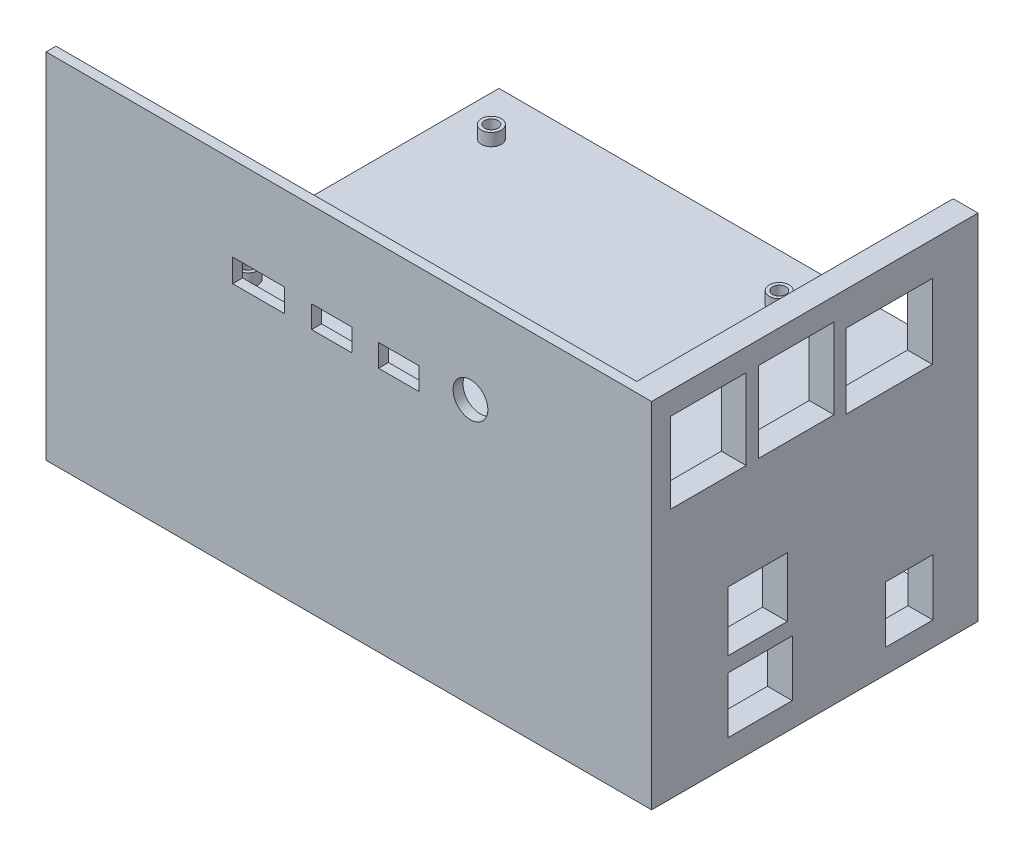
from build123d import *

# Parameters (mm, degrees)
MAIN_BODY_DEPTH                = 70
FAN_MOUNTS_DEPTH               = 5
SKETCH6_R                      = 30
FAN_HOLE_DEPTH                 = 5
SKETCH7_W                      = 65
SKETCH7_H                      = 1.25
BOTTOM_PLATE_DEPTH             = 127
SKETCH1_3_R                    = 2.54
SKETCH1_3_R_2                  = 1.6
ARDUINO_MOUNT_1_DEPTH          = 2.5
SKETCH1_4_R                    = 2.54
SKETCH1_4_R_2                  = 1.6
ARDUINO_MOUNT_2_DEPTH          = 2.5
SKETCH1_5_R                    = 2.54
SKETCH1_5_R_2                  = 1.6
ARDUINO_MOUNT_3_DEPTH          = 2.5
SKETCH1_6_R                    = 2.54
SKETCH1_6_R_2                  = 1.6
ARDUINO_MOUNT_4_DEPTH          = 2.5
SKETCH9_W                      = 12.985
SKETCH9_H                      = 11.3
ARDUINO_USB_B_DEPTH            = 5
SKETCH12_W                     = 9.5
SKETCH12_H                     = 11.4
ARDUION_POWER_HOLE_DEPTH       = 5
SKETCH28_W                     = 12
SKETCH28_H                     = 12
READER_COAX_DEPTH              = 5
SEPARATING_PLATE_DEPTH         = 62.5
PI_SEATS_DEPTH                 = 2.5
SKETCH14_W                     = 17.35
SKETCH14_H                     = 15
PI_ETHERNET_DEPTH              = 5
SKETCH16_W                     = 15.2
SKETCH16_H                     = 16.2
PI_USB_3_0_DEPTH               = 5
SKETCH18_W                     = 15.2
SKETCH18_H                     = 16.2
PI_USB_2_0_DEPTH               = 5
SKETCH19_R                     = 3.5
PI_AUDIO_PORT_DEPTH            = 2
SKETCH20_W                     = 8.1
SKETCH20_H                     = 4.5
PI_MICRO_HDMI_RIGHT_DEPTH      = 2
SKETCH21_W                     = 8.1
SKETCH21_H                     = 4.5
PI_MICRO_HDMI_LEFT_DEPTH       = 2
SKETCH22_W                     = 10.4
SKETCH22_H                     = 4.65
PI_USB_C_DEPTH                 = 2
SIDE_PANEL_OUT_DEPTH           = 1.5
SKETCH27_W                     = 127
SKETCH27_H                     = 71.25
SKETCH27_R                     = 3.5
SKETCH27_W_2                   = 8.1
SKETCH27_H_2                   = 4.5
SKETCH27_W_3                   = 10.4
SKETCH27_H_3                   = 4.65
MAKING_I_O_PANEL_THICKER_DEPTH = 0.75
REMOVE_START                   = -71.25
SKETCH35_W                     = 5
SKETCH35_H                     = 65.75
REMOVE_FAN_DEPTH               = 71.25


with BuildPart() as part:
    # Sketch1 → main body (new body)
    with BuildSketch(Plane(origin=(0, 0, 0), x_dir=(1, 0, 0), z_dir=(0, 1, 0))):
        Polygon((-46.184210526, 37.557328438), (-46.184210526, 38.807328438), (-62.226649752, 38.807328438), (-62.226649752, 31.576979723), (-57.226649752, 31.576979723), (-57.226649752, 37.557328438), align=None)
        Polygon((64.773350248, 38.807328438), (-46.184210526, 38.807328438), (-46.184210526, 37.557328438), (59.773350248, 37.557328438), (59.773350248, -24.942671562), (-57.226649752, -24.942671562), (-57.226649752, 31.576979723), (-62.226649752, 31.576979723), (-62.226649752, -26.192671562), (64.773350248, -26.192671562), align=None)
    extrude(amount=MAIN_BODY_DEPTH)

    # Sketch25 → fan mounts (cut)
    with BuildSketch(Plane.ZY.offset(62.226649752)):
        with BuildLine():
            Line((-31.333787438, 60), (-31.333787438, 62.15))
            ThreePointArc((-31.333787438, 62.15), (-32.854067018, 61.52027958), (-33.483787438, 60))
            Line((-33.483787438, 60), (-31.333787438, 60))
        make_face()
        with BuildLine():
            Line((-31.333787438, 57.85), (-31.333787438, 60))
            Line((-31.333787438, 60), (-33.483787438, 60))
            ThreePointArc((-33.483787438, 60), (-32.854067018, 58.47972042), (-31.333787438, 57.85))
        make_face()
        with BuildLine():
            Line((-29.183787438, 60), (-31.333787438, 60))
            Line((-31.333787438, 60), (-31.333787438, 57.85))
            ThreePointArc((-31.333787438, 57.85), (-29.813507858, 58.47972042), (-29.183787438, 60))
        make_face()
        with BuildLine():
            ThreePointArc((-29.183787438, 60), (-29.813507858, 61.52027958), (-31.333787438, 62.15))
            Line((-31.333787438, 62.15), (-31.333787438, 60))
            Line((-31.333787438, 60), (-29.183787438, 60))
        make_face()
        with BuildLine():
            ThreePointArc((-29.183787438, 10), (-29.813507858, 11.52027958), (-31.333787438, 12.15))
            Line((-31.333787438, 12.15), (-31.333787438, 10))
            Line((-31.333787438, 10), (-29.183787438, 10))
        make_face()
        with BuildLine():
            Line((-31.333787438, 10), (-31.333787438, 12.15))
            ThreePointArc((-31.333787438, 12.15), (-32.854067018, 8.47972042), (-29.183787438, 10))
            Line((-29.183787438, 10), (-31.333787438, 10))
        make_face()
        with BuildLine():
            ThreePointArc((20.816212562, 10), (20.186492142, 11.52027958), (18.666212562, 12.15))
            Line((18.666212562, 12.15), (18.666212562, 10))
            Line((18.666212562, 10), (16.516212562, 10))
            ThreePointArc((16.516212562, 10), (18.666212562, 7.85), (20.816212562, 10))
        make_face()
        with BuildLine():
            Line((18.666212562, 10), (18.666212562, 12.15))
            ThreePointArc((18.666212562, 12.15), (17.145932982, 11.52027958), (16.516212562, 10))
            Line((16.516212562, 10), (18.666212562, 10))
        make_face()
        with BuildLine():
            ThreePointArc((20.816212562, 60), (18.666212562, 62.15), (16.516212562, 60))
            Line((16.516212562, 60), (18.666212562, 60))
            Line((18.666212562, 60), (18.666212562, 57.85))
            ThreePointArc((18.666212562, 57.85), (20.186492142, 58.47972042), (20.816212562, 60))
        make_face()
        with BuildLine():
            Line((18.666212562, 60), (16.516212562, 60))
            ThreePointArc((16.516212562, 60), (17.145932982, 58.47972042), (18.666212562, 57.85))
            Line((18.666212562, 57.85), (18.666212562, 60))
        make_face()
    extrude(amount=-FAN_MOUNTS_DEPTH, mode=Mode.SUBTRACT)

    # Sketch6 → fan hole (cut)
    with BuildSketch(Plane.ZY.offset(62.226649752)):
        with Locations((-6.307328438, 34.968)):
            Circle(SKETCH6_R)
    extrude(amount=-FAN_HOLE_DEPTH, mode=Mode.SUBTRACT)

    # Sketch7 → bottom plate (add)
    with BuildSketch(Plane.ZY.offset(62.226649752)):
        with Locations((-6.307328438, -0.625)):
            Rectangle(SKETCH7_W, SKETCH7_H)
    extrude(amount=-BOTTOM_PLATE_DEPTH)

    # Sketch1_3 → arduino mount 1 (add)
    with BuildSketch(Plane(origin=(0, 0, 0), x_dir=(1, 0, 0), z_dir=(0, 1, 0))):
        with Locations((-7.472752953, 25.505147863)):
            Circle(SKETCH1_3_R)
        with Locations((-7.472752953, 25.505147863)):
            Circle(SKETCH1_3_R_2, mode=Mode.SUBTRACT)
    extrude(amount=ARDUINO_MOUNT_1_DEPTH)

    # Sketch1_4 → arduino mount 2 (add)
    with BuildSketch(Plane(origin=(0, 0, 0), x_dir=(1, 0, 0), z_dir=(0, 1, 0))):
        with Locations((-7.472752953, -2.394852137)):
            Circle(SKETCH1_4_R)
        with Locations((-7.472752953, -2.394852137)):
            Circle(SKETCH1_4_R_2, mode=Mode.SUBTRACT)
    extrude(amount=ARDUINO_MOUNT_2_DEPTH)

    # Sketch1_5 → arduino mount 3 (add)
    with BuildSketch(Plane(origin=(0, 0, 0), x_dir=(1, 0, 0), z_dir=(0, 1, 0))):
        with Locations((44.427247047, 30.205147863)):
            Circle(SKETCH1_5_R)
        with Locations((44.427247047, 30.205147863)):
            Circle(SKETCH1_5_R_2, mode=Mode.SUBTRACT)
    extrude(amount=ARDUINO_MOUNT_3_DEPTH)

    # Sketch1_6 → arduino mount 4 (add)
    with BuildSketch(Plane(origin=(0, 0, 0), x_dir=(1, 0, 0), z_dir=(0, 1, 0))):
        with Locations((43.327247047, -17.594852137)):
            Circle(SKETCH1_6_R)
        with Locations((43.327247047, -17.594852137)):
            Circle(SKETCH1_6_R_2, mode=Mode.SUBTRACT)
    extrude(amount=ARDUINO_MOUNT_4_DEPTH)

    # Sketch9 → arduino usb b (cut)
    with BuildSketch(Plane(origin=(64.773350248, 0, 0), x_dir=(0, 0, -1), z_dir=(1, 0, 0))):
        with Locations((-5.100171562, 9.3)):
            Rectangle(SKETCH9_W, SKETCH9_H)
    extrude(amount=-ARDUINO_USB_B_DEPTH, mode=Mode.SUBTRACT)

    # Sketch12 → arduion power hole (cut)
    with BuildSketch(Plane(origin=(64.773350248, 0, 0), x_dir=(0, 0, -1), z_dir=(1, 0, 0))):
        with Locations((24.957328438, 9.25)):
            Rectangle(SKETCH12_W, SKETCH12_H)
    extrude(amount=-ARDUION_POWER_HOLE_DEPTH, mode=Mode.SUBTRACT)

    # Sketch28 → reader coax (cut)
    with BuildSketch(Plane(origin=(64.773350248, 0, 0), x_dir=(0, 0, -1), z_dir=(1, 0, 0))):
        with Locations((-5.592671562, 23.95)):
            Rectangle(SKETCH28_W, SKETCH28_H)
    extrude(amount=-READER_COAX_DEPTH, mode=Mode.SUBTRACT)

    # clearance → separating plate (add)
    with BuildSketch(Plane.XY.offset(-37.557328438)):
        Polygon((21.752865488, 43), (59.773350248, 43), (59.773350248, 45), (-30.226649752, 45), (-30.226649752, 43), align=None)
    extrude(amount=SEPARATING_PLATE_DEPTH)

    # Sketch24 → pi seats (add)
    with BuildSketch(Plane(origin=(0, 45, 0), x_dir=(1, 0, 0), z_dir=(0, 1, 0))):
        with BuildLine():
            Line((-22.218946752, 29.111418438), (-22.218946752, 29.761418438))
            ThreePointArc((-22.218946752, 29.761418438), (-23.633160315, 29.175632), (-24.218946752, 27.761418438))
            Line((-24.218946752, 27.761418438), (-23.568946752, 27.761418438))
            ThreePointArc((-23.568946752, 27.761418438), (-23.173540907, 28.716012593), (-22.218946752, 29.111418438))
        make_face()
        with BuildLine():
            ThreePointArc((-20.218946752, 27.761418438), (-20.80473319, 29.175632), (-22.218946752, 29.761418438))
            Line((-22.218946752, 29.761418438), (-22.218946752, 29.111418438))
            ThreePointArc((-22.218946752, 29.111418438), (-21.264352598, 28.716012593), (-20.868946752, 27.761418438))
            Line((-20.868946752, 27.761418438), (-20.218946752, 27.761418438))
        make_face()
        with BuildLine():
            ThreePointArc((-22.218946752, 25.761418438), (-20.80473319, 26.347204876), (-20.218946752, 27.761418438))
            Line((-20.218946752, 27.761418438), (-20.868946752, 27.761418438))
            ThreePointArc((-20.868946752, 27.761418438), (-21.264352598, 26.806824283), (-22.218946752, 26.411418438))
            Line((-22.218946752, 26.411418438), (-22.218946752, 25.761418438))
        make_face()
        with BuildLine():
            Line((-23.568946752, 27.761418438), (-24.218946752, 27.761418438))
            ThreePointArc((-24.218946752, 27.761418438), (-23.633160315, 26.347204876), (-22.218946752, 25.761418438))
            Line((-22.218946752, 25.761418438), (-22.218946752, 26.411418438))
            ThreePointArc((-22.218946752, 26.411418438), (-23.173540907, 26.806824283), (-23.568946752, 27.761418438))
        make_face()
        with BuildLine():
            ThreePointArc((-20.218946752, -21.238581562), (-20.80473319, -19.824368), (-22.218946752, -19.238581562))
            Line((-22.218946752, -19.238581562), (-22.218946752, -19.888581562))
            ThreePointArc((-22.218946752, -19.888581562), (-21.264352598, -20.283987407), (-20.868946752, -21.238581562))
            Line((-20.868946752, -21.238581562), (-20.218946752, -21.238581562))
        make_face()
        with BuildLine():
            Line((-22.218946752, -19.888581562), (-22.218946752, -19.238581562))
            ThreePointArc((-22.218946752, -19.238581562), (-23.633160315, -22.652795124), (-20.218946752, -21.238581562))
            Line((-20.218946752, -21.238581562), (-20.868946752, -21.238581562))
            ThreePointArc((-20.868946752, -21.238581562), (-23.173540907, -22.193175717), (-22.218946752, -19.888581562))
        make_face()
        with BuildLine():
            ThreePointArc((37.781053248, 27.761418438), (35.781053248, 29.761418438), (33.781053248, 27.761418438))
            Line((33.781053248, 27.761418438), (34.431053248, 27.761418438))
            ThreePointArc((34.431053248, 27.761418438), (35.781053248, 29.111418438), (37.131053248, 27.761418438))
            ThreePointArc((37.131053248, 27.761418438), (36.735647402, 26.806824283), (35.781053248, 26.411418438))
            Line((35.781053248, 26.411418438), (35.781053248, 25.761418438))
            ThreePointArc((35.781053248, 25.761418438), (37.19526681, 26.347204876), (37.781053248, 27.761418438))
        make_face()
        with BuildLine():
            Line((34.431053248, 27.761418438), (33.781053248, 27.761418438))
            ThreePointArc((33.781053248, 27.761418438), (34.366839685, 26.347204876), (35.781053248, 25.761418438))
            Line((35.781053248, 25.761418438), (35.781053248, 26.411418438))
            ThreePointArc((35.781053248, 26.411418438), (34.826459093, 26.806824283), (34.431053248, 27.761418438))
        make_face()
        with BuildLine():
            ThreePointArc((37.781053248, -21.238581562), (37.19526681, -19.824368), (35.781053248, -19.238581562))
            Line((35.781053248, -19.238581562), (35.781053248, -19.888581562))
            ThreePointArc((35.781053248, -19.888581562), (36.735647402, -20.283987407), (37.131053248, -21.238581562))
            ThreePointArc((37.131053248, -21.238581562), (35.781053248, -22.588581562), (34.431053248, -21.238581562))
            Line((34.431053248, -21.238581562), (33.781053248, -21.238581562))
            ThreePointArc((33.781053248, -21.238581562), (35.781053248, -23.238581562), (37.781053248, -21.238581562))
        make_face()
        with BuildLine():
            Line((35.781053248, -19.888581562), (35.781053248, -19.238581562))
            ThreePointArc((35.781053248, -19.238581562), (34.366839685, -19.824368), (33.781053248, -21.238581562))
            Line((33.781053248, -21.238581562), (34.431053248, -21.238581562))
            ThreePointArc((34.431053248, -21.238581562), (34.826459093, -20.283987407), (35.781053248, -19.888581562))
        make_face()
    extrude(amount=PI_SEATS_DEPTH)

    # Sketch14 → pi ethernet (cut)
    with BuildSketch(Plane(origin=(64.773350248, 0, 0), x_dir=(0, 0, -1), z_dir=(1, 0, 0))):
        with Locations((20.932328438, 55.7)):
            Rectangle(SKETCH14_W, SKETCH14_H)
    extrude(amount=-PI_ETHERNET_DEPTH, mode=Mode.SUBTRACT)

    # Sketch16 → pi usb 3.0 (cut)
    with BuildSketch(Plane(origin=(64.773350248, 0, 0), x_dir=(0, 0, -1), z_dir=(1, 0, 0))):
        with Locations((2.207328438, 57.4)):
            Rectangle(SKETCH16_W, SKETCH16_H)
    extrude(amount=-PI_USB_3_0_DEPTH, mode=Mode.SUBTRACT)

    # Sketch18 → pi usb 2.0 (cut)
    with BuildSketch(Plane(origin=(64.773350248, 0, 0), x_dir=(0, 0, -1), z_dir=(1, 0, 0))):
        with Locations((-15.492671562, 57.4)):
            Rectangle(SKETCH18_W, SKETCH18_H)
    extrude(amount=-PI_USB_2_0_DEPTH, mode=Mode.SUBTRACT)

    # Sketch19 → pi audio port (cut)
    with BuildSketch(Plane.XY.offset(26.192671562)):
        with Locations((28.281053248, 52.068376)):
            Circle(SKETCH19_R)
    extrude(amount=-PI_AUDIO_PORT_DEPTH, mode=Mode.SUBTRACT)

    # Sketch20 → pi micro hdmi right (cut)
    with BuildSketch(Plane.XY.offset(26.192671562)):
        with Locations((13.823350248, 50.55)):
            Rectangle(SKETCH20_W, SKETCH20_H)
    extrude(amount=-PI_MICRO_HDMI_RIGHT_DEPTH, mode=Mode.SUBTRACT)

    # Sketch21 → pi micro hdmi left (cut)
    with BuildSketch(Plane.XY.offset(26.192671562)):
        with Locations((0.323350248, 50.55)):
            Rectangle(SKETCH21_W, SKETCH21_H)
    extrude(amount=-PI_MICRO_HDMI_LEFT_DEPTH, mode=Mode.SUBTRACT)

    # Sketch22 → pi usb c (cut)
    with BuildSketch(Plane.XY.offset(26.192671562)):
        with Locations((-14.426649752, 50.675)):
            Rectangle(SKETCH22_W, SKETCH22_H)
    extrude(amount=-PI_USB_C_DEPTH, mode=Mode.SUBTRACT)

    # Sketch26 → side panel out (cut)
    with BuildSketch(Plane(origin=(0, 0, -38.807328438), x_dir=(-1, 0, 0), z_dir=(0, 0, -1))):
        Polygon((57.226649752, 70), (-59.773350248, 70), (-59.773350248, 52.362121809), (-59.773350248, 0), (-23.880559262, 0), (57.226649752, 0), (57.226649752, 48.247981632), align=None)
    extrude(amount=-SIDE_PANEL_OUT_DEPTH, mode=Mode.SUBTRACT)

    # Sketch27 → making i_o panel thicker (add)
    with BuildSketch(Plane.XY.offset(26.192671562)):
        with Locations((1.273350248, 34.375)):
            Rectangle(SKETCH27_W, SKETCH27_H)
        with Locations((28.281053248, 52.068376)):
            Circle(SKETCH27_R, mode=Mode.SUBTRACT)
        with Locations((13.823350248, 50.55)):
            Rectangle(SKETCH27_W_2, SKETCH27_H_2, mode=Mode.SUBTRACT)
        with Locations((0.323350248, 50.55)):
            Rectangle(SKETCH27_W_2, SKETCH27_H_2, mode=Mode.SUBTRACT)
        with Locations((-14.426649752, 50.675)):
            Rectangle(SKETCH27_W_3, SKETCH27_H_3, mode=Mode.SUBTRACT)
    extrude(amount=MAKING_I_O_PANEL_THICKER_DEPTH)

    # Sketch35 → remove fan (cut)
    with BuildSketch(Plane(origin=(0, 70, 0), x_dir=(1, 0, 0), z_dir=(0, 1, 0)).offset(REMOVE_START)):
        with Locations((-59.726649752, 5.932328438)):
            Rectangle(SKETCH35_W, SKETCH35_H)
    extrude(amount=REMOVE_FAN_DEPTH, mode=Mode.SUBTRACT)


solid = part.part
